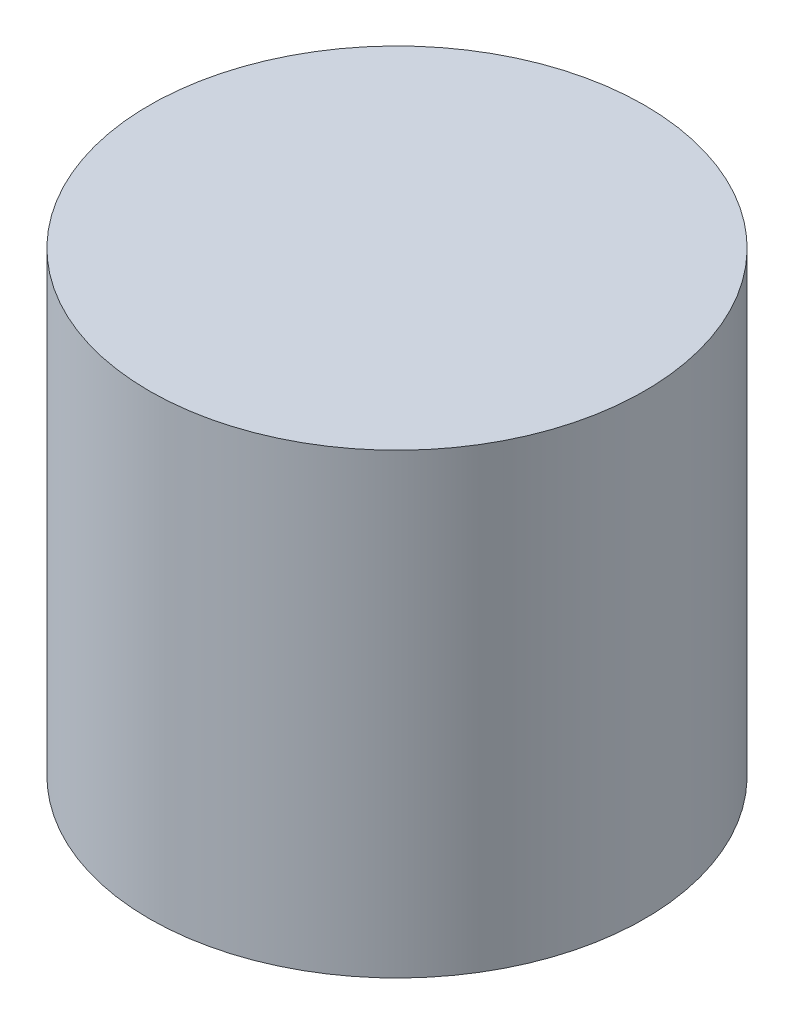
from build123d import *

# Parameters (mm, degrees)
SKETCH1_R           = 8.255
SKETCH1_R_2         = 6.35
BOSS_EXTRUDE1_DEPTH = 12.7
SKETCH2_R           = 8.255
BOSS_EXTRUDE2_DEPTH = 2.54
CHAMFER1_SIZE       = 0.508


with BuildPart() as part:
    # Sketch1 → Boss-Extrude1 (new body)
    with BuildSketch(Plane(origin=(0, 0, 0), x_dir=(1, 0, 0), z_dir=(0, 1, 0))):
        with Locations(Location((0, 0, 0), (0, 0, 270))):  # turned: the seam where the file's is
            Circle(SKETCH1_R)
        with Locations(Location((0, 0, 0), (0, 0, 270))):  # turned: the seam where the file's is
            Circle(SKETCH1_R_2, mode=Mode.SUBTRACT)
    extrude(amount=BOSS_EXTRUDE1_DEPTH)

    # Sketch2 → Boss-Extrude2 (add)
    with BuildSketch(Plane(origin=(0, 12.7, 0), x_dir=(1, 0, 0), z_dir=(0, 1, 0))):
        with Locations(Location((0, 0, 0), (0, 0, 270))):  # turned: the seam where the file's is
            Circle(SKETCH2_R)
    extrude(amount=BOSS_EXTRUDE2_DEPTH)

    # Chamfer1
    chamfer1_edges = [part.edges().sort_by_distance(p)[0] for p in [
        (0, 0, -6.35),
    ]]
    chamfer(chamfer1_edges, length=CHAMFER1_SIZE)


solid = part.part
